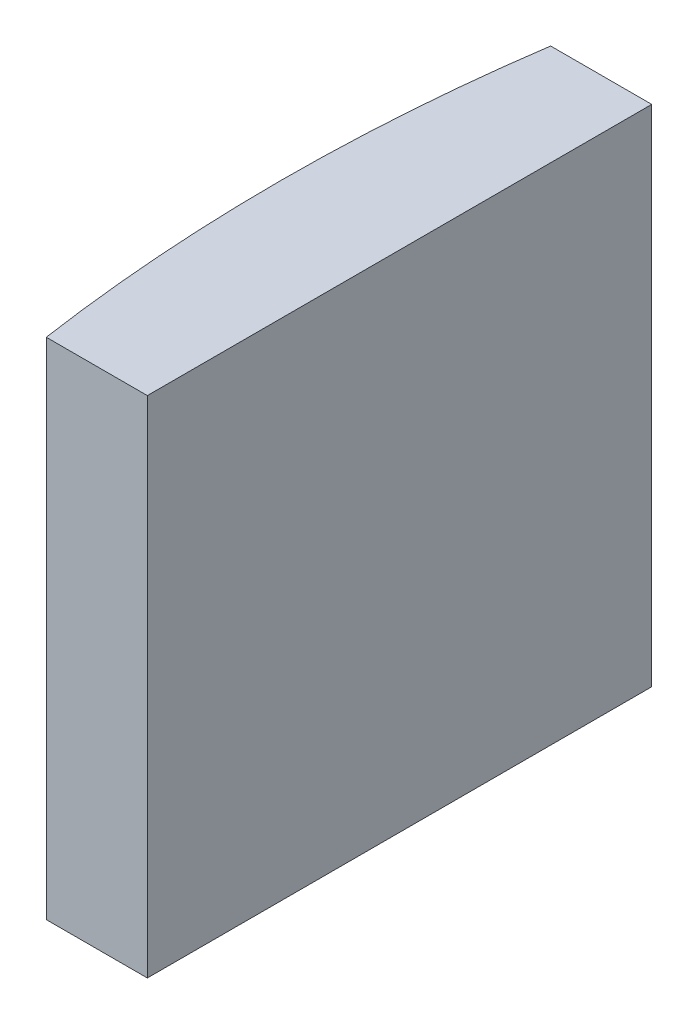
from build123d import *

# Parameters (mm, degrees)
EXTRUDE_1_DEPTH = 10


with BuildPart() as part:
    # 草图1 → 凸台-拉伸1 (new body)
    with BuildSketch(Plane(origin=(0, 0, 0), x_dir=(1, 0, 0), z_dir=(0, 1, 0))):
        with BuildLine():
            Line((-29.628946383, 5), (-27.624795665, 5))
            Line((-27.624795665, 5), (-27.624795665, -5))
            Line((-27.624795665, -5), (-29.628946383, -5))
            ThreePointArc((-29.628946383, -5), (-29.994795665, 0), (-29.628946383, 5))
        make_face()
    extrude(amount=EXTRUDE_1_DEPTH)


solid = part.part
